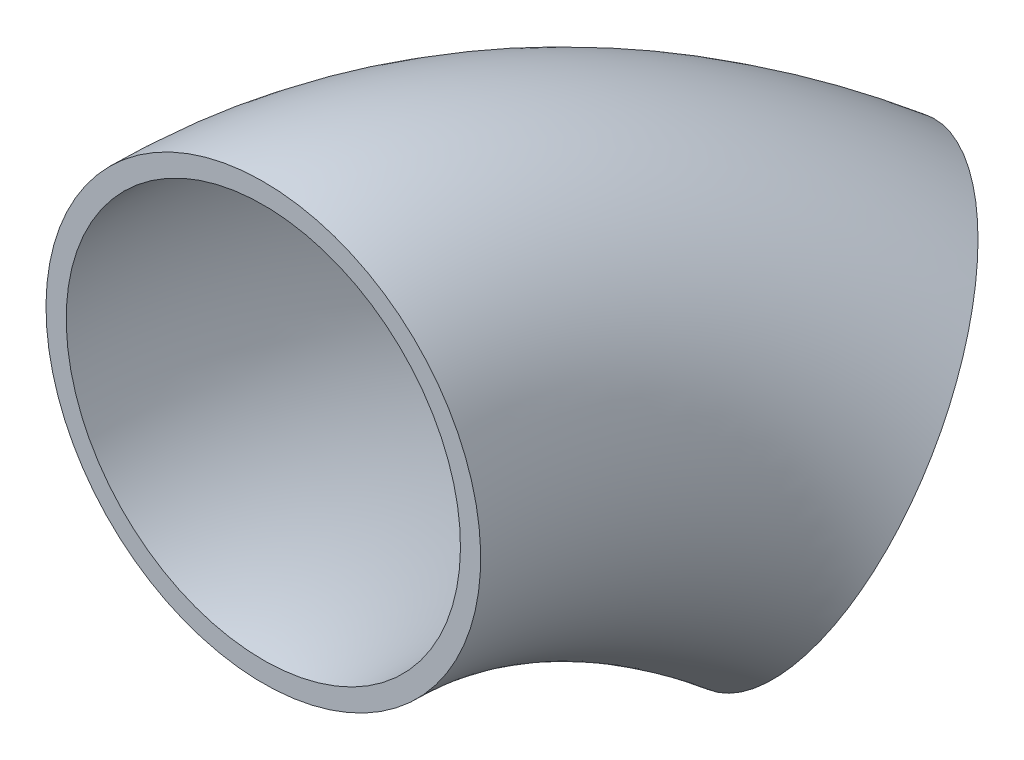
from build123d import *

# Parameters (mm, degrees)
PIPESKETCH_R   = 136.525
PIPESKETCH_R_2 = 123.825


with BuildPart() as part:
    # Sweep1: sweep along a curve in space
    with BuildLine() as sweep1_path:
        ThreePointArc((0, 0, 0), (20.507438823, -20.507438823, -145.802387731), (78.907683632, -78.907683632, -269.407683632))
    # PipeSketch → Sweep1 (sweep)
    with BuildSketch(Plane.XY):
        Circle(PIPESKETCH_R)
        Circle(PIPESKETCH_R_2, mode=Mode.SUBTRACT)
    sweep(path=sweep1_path.line)


solid = part.part
